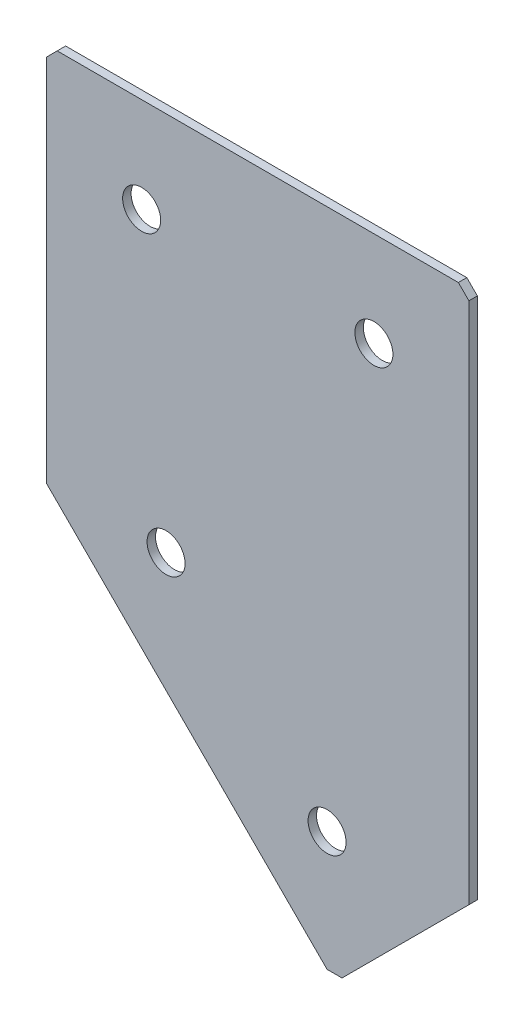
from build123d import *

# Parameters (mm, degrees)
EXTRUDE_1_DEPTH   = 2
HOLE_WIZARD_M81_D = 9
CHAMFER_1_SIZE    = 2.5


with BuildPart() as part:
    # Эскиз3 → Бобышка-Вытянуть1 (new body)
    with BuildSketch(Plane(origin=(0, 0, 0), x_dir=(1, 0, 0), z_dir=(0, 0, -1))):
        Polygon((0, 0), (100, 0), (100, 126.360389693), (68.180194847, 158.180194847), (0, 90), align=None)
    extrude(amount=EXTRUDE_1_DEPTH)

    # Отверстие с зазором M81 (through all)
    with Locations(Plane(origin=(0, 0, -2), x_dir=(1, 0, 0), z_dir=(0, 0, -1))):
        with Locations((22.5, 22.5), (77.5, 22.5), (28.284271247, 90), (66.412427894, 128.128156646)):
            Hole(HOLE_WIZARD_M81_D / 2)

    # Фаска1
    chamfer_1_edges = [part.edges().sort_by_distance(p)[0] for p in [
        (68.180194847, -158.180194847, -1),
        (100, 0, -1),
        (0, 0, -1),
    ]]
    chamfer(chamfer_1_edges, length=CHAMFER_1_SIZE)


solid = part.part
